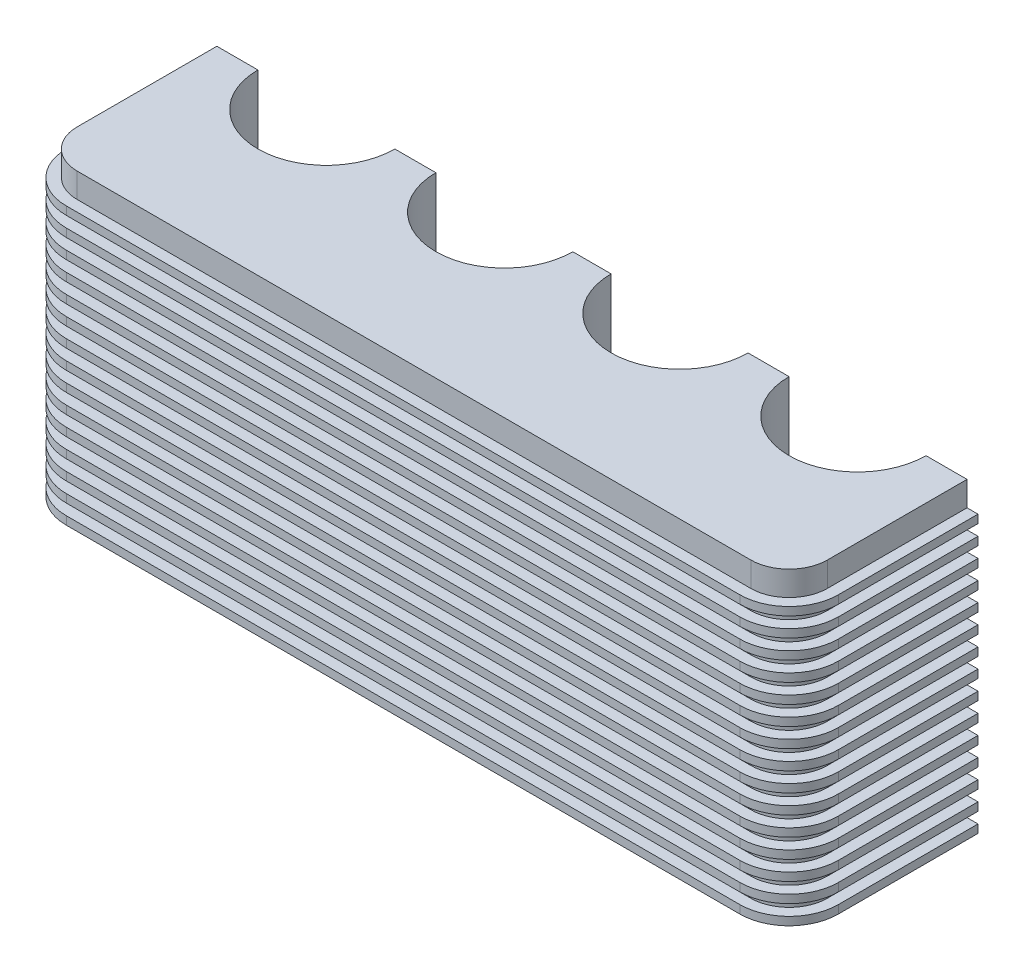
from build123d import *

# Parameters (mm, degrees)
BOSS_EXTRUDE1_DEPTH = 110
BOSS_EXTRUDE2_DEPTH = 3
LPATTERN5_COUNT     = 15
LPATTERN5_PITCH     = 7


with BuildPart() as part:
    # Sketch1 → Boss-Extrude1 (new body)
    with BuildSketch(Plane(origin=(0, 0, 0), x_dir=(1, 0, 0), z_dir=(0, 1, 0))):
        with BuildLine():
            ThreePointArc((57, 0), (32, -25), (7, 0))
            Line((7, 0), (-7, 0))
            ThreePointArc((-7, 0), (-32, -25), (-57, 0))
            Line((-57, 0), (-72, 0))
            ThreePointArc((-72, 0), (-97, -25), (-122, 0))
            Line((-122, 0), (-137, 0))
            Line((-137, 0), (-137, -51))
            ThreePointArc((-137, -51), (-132.899494937, -60.899494937), (-123, -65))
            Line((-123, -65), (123, -65))
            ThreePointArc((123, -65), (132.899494937, -60.899494937), (137, -51))
            Line((137, -51), (137, 0))
            Line((137, 0), (122, 0))
            ThreePointArc((122, 0), (97, -25), (72, 0))
            Line((72, 0), (57, 0))
        make_face()
    extrude(amount=BOSS_EXTRUDE1_DEPTH)

    # Sketch2 → Boss-Extrude2 (add)
    with BuildSketch(Plane.XZ):
        with BuildLine():
            Line((123, 69), (-123, 69))
            ThreePointArc((-123, 69), (-135.727922061, 63.727922061), (-141, 51))
            Line((-141, 51), (-141, 0))
            Line((-141, 0), (-137, 0))
            Line((-137, 0), (-137, 51))
            ThreePointArc((-137, 51), (-132.899494937, 60.899494937), (-123, 65))
            Line((-123, 65), (123, 65))
            ThreePointArc((123, 65), (132.899494937, 60.899494937), (137, 51))
            Line((137, 51), (137, 0))
            Line((137, 0), (141, 0))
            Line((141, 0), (141, 51))
            ThreePointArc((141, 51), (135.727922061, 63.727922061), (123, 69))
        make_face()
    boss_extrude2 = extrude(amount=-BOSS_EXTRUDE2_DEPTH)

    # LPattern5: Boss-Extrude2 ×15
    with Locations(*[(0, i * LPATTERN5_PITCH, 0) for i in range(1, LPATTERN5_COUNT)]):
        add(boss_extrude2)


solid = part.part
